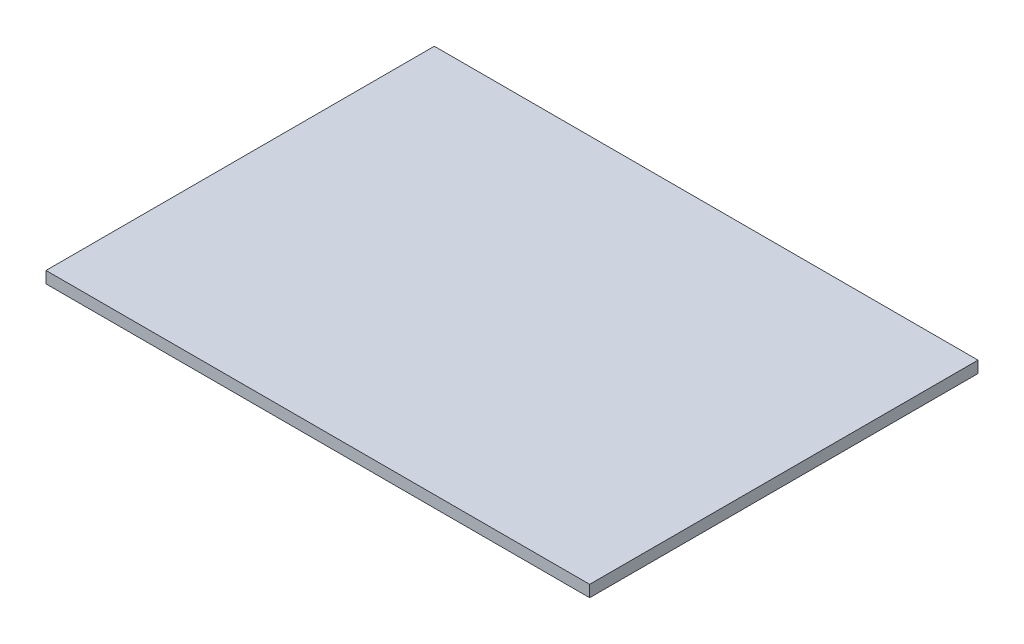
from build123d import *

# Parameters (mm, degrees)
ESBO_O1_W                = 70
ESBO_O1_H                = 50
RESSALTO_EXTRUS_O1_DEPTH = 1.5


with BuildPart() as part:
    # Esboço1 → Ressalto-extrusão1 (new body)
    with BuildSketch(Plane(origin=(0, 0, 0), x_dir=(1, 0, 0), z_dir=(0, 1, 0))):
        Rectangle(ESBO_O1_W, ESBO_O1_H)
    extrude(amount=RESSALTO_EXTRUS_O1_DEPTH)


solid = part.part
